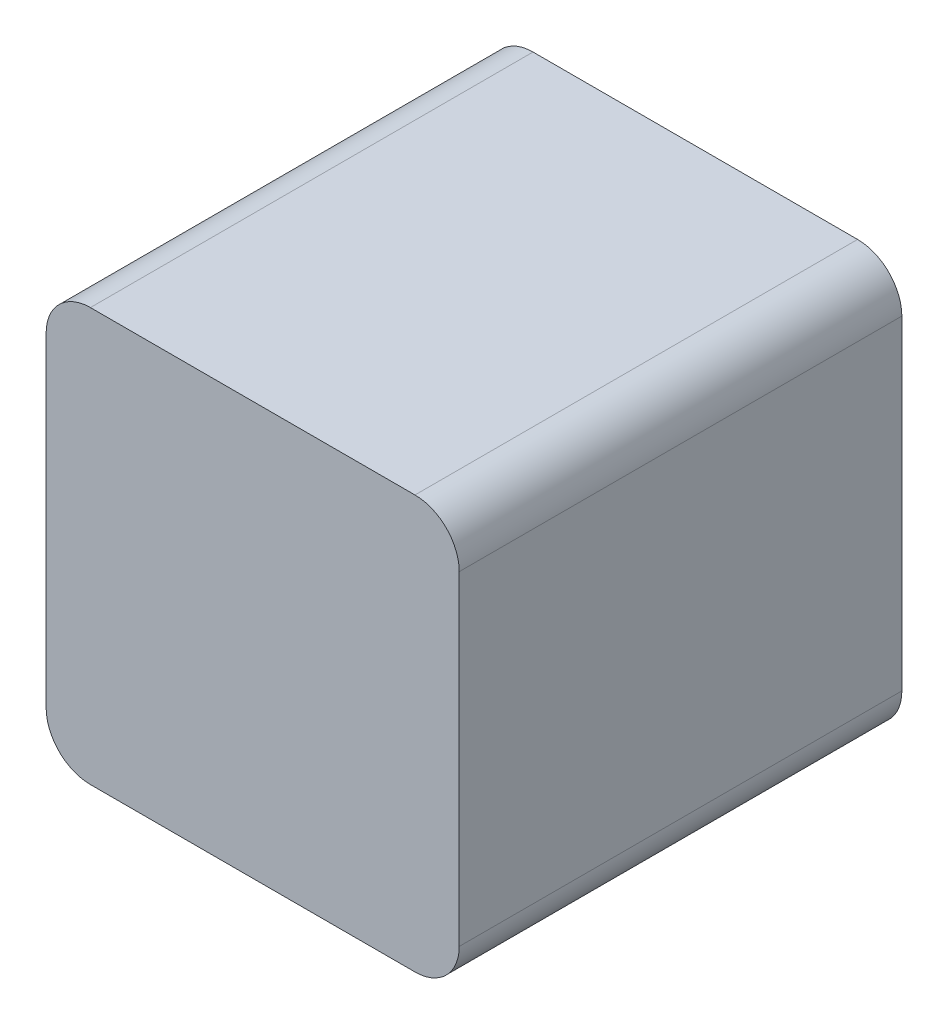
from build123d import *

# Parameters (mm, degrees)
SKETCH1_W           = 28
SKETCH1_H           = 28
BOSS_EXTRUDE1_DEPTH = 15
SKETCH2_W           = 15
SKETCH2_H           = 7
BOSS_EXTRUDE2_DEPTH = 1.5
FILLET1_R           = 3


with BuildPart() as part:
    # Sketch1 → Boss-Extrude1 (new body, symmetric)
    with BuildSketch(Plane.XY):
        Rectangle(SKETCH1_W, SKETCH1_H)
    extrude(amount=BOSS_EXTRUDE1_DEPTH, both=True)

    # Sketch2 → Boss-Extrude2 (add, symmetric)
    with BuildSketch(Plane.XZ.offset(14)):
        with Locations((0, -11.5)):
            Rectangle(SKETCH2_W, SKETCH2_H)
    extrude(amount=BOSS_EXTRUDE2_DEPTH, both=True)

    # Fillet1
    fillet1_edges = [part.edges().sort_by_distance(p)[0] for p in [
        (14, -14, 0),
        (-14, -14, 0),
        (-14, 14, 0),
        (14, 14, 0),
    ]]
    fillet(fillet1_edges, radius=FILLET1_R)


solid = part.part
